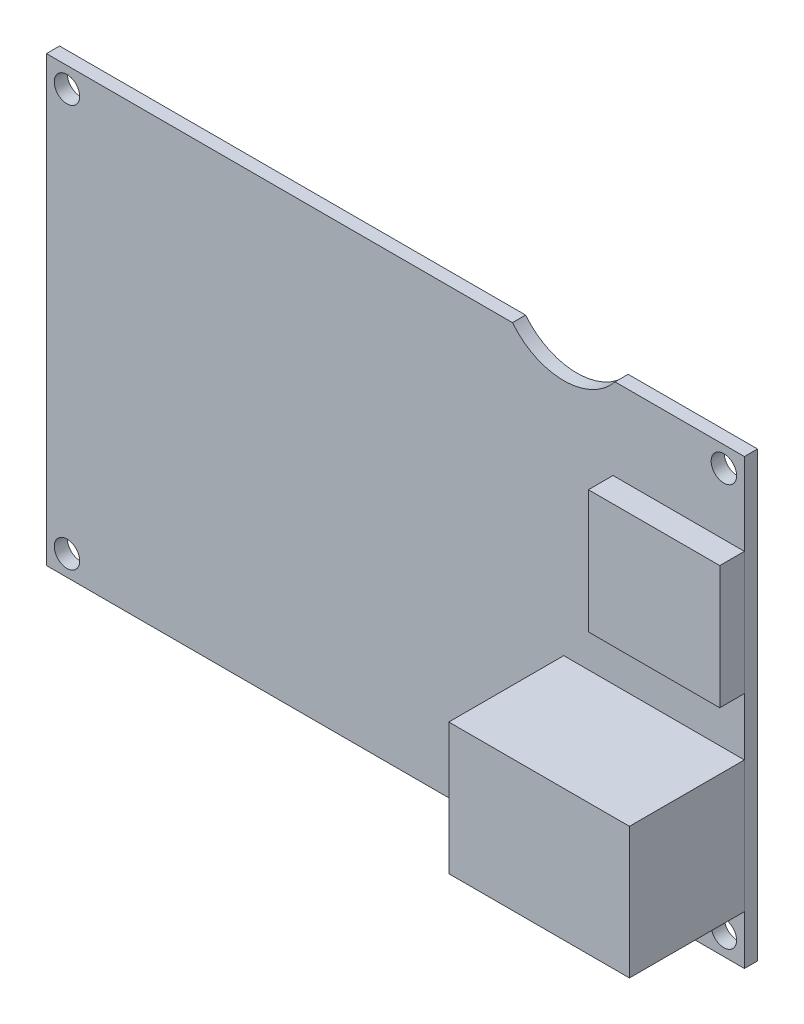
from build123d import *

# Parameters (mm, degrees)
SKETCH_1_W          = 85
SKETCH_1_H          = 54
SKETCH_1_R          = 1.55
EXTRUDE_1_DEPTH     = 1.6
SKETCH_2_W          = 22
SKETCH_2_H          = 16
EXTRUDE_2_DEPTH     = 14
SKETCH_2_3_W        = 16
SKETCH_2_3_H        = 15
EXTRUDE_3_DEPTH     = 3
CUT_EXTRUDE_1_DEPTH = 102.671038157


with BuildPart() as part:
    # Эскиз1 → Бобышка-Вытянуть1 (new body)
    with BuildSketch(Plane.XY):
        with Locations((42.5, 27)):
            Rectangle(SKETCH_1_W, SKETCH_1_H)
        with Locations((2.5, 51.5)):
            Circle(SKETCH_1_R, mode=Mode.SUBTRACT)
        with Locations((82.5, 51.5)):
            Circle(SKETCH_1_R, mode=Mode.SUBTRACT)
        with Locations((82.5, 2.5)):
            Circle(SKETCH_1_R, mode=Mode.SUBTRACT)
        with Locations((2.5, 2.5)):
            Circle(SKETCH_1_R, mode=Mode.SUBTRACT)
    extrude(amount=EXTRUDE_1_DEPTH)

    # Эскиз5 → Вырез-Вытянуть1 (cut, through all)
    with BuildSketch(Plane.XY.offset(1.6)):
        with BuildLine():
            Line((-59.259445708, 198.901998746), (56.755002002, 54))
            ThreePointArc((56.755002002, 54), (63, 51), (69.244997998, 54))
            Line((69.244997998, 54), (185.259445708, 198.901998746))
            Line((185.259445708, 198.901998746), (185.259445708, 570.148231416))
            Line((185.259445708, 570.148231416), (-59.259445708, 570.148231416))
            Line((-59.259445708, 570.148231416), (-59.259445708, 198.901998746))
        make_face()
    extrude(amount=-CUT_EXTRUDE_1_DEPTH, mode=Mode.SUBTRACT)


with BuildPart() as body_2:
    # Эскиз2 → Бобышка-Вытянуть2 (new body)
    with BuildSketch(Plane(origin=(0, 0, 1.6), x_dir=(-1, 0, 0), z_dir=(0, 0, -1))):
        with Locations((-74, 14)):
            Rectangle(SKETCH_2_W, SKETCH_2_H)
    extrude(amount=-EXTRUDE_2_DEPTH)


with BuildPart() as body_3:
    # Эскиз2<3> → Бобышка-Вытянуть3 (new body)
    with BuildSketch(Plane(origin=(0, 0, 1.6), x_dir=(-1, 0, 0), z_dir=(0, 0, -1))):
        with Locations((-77, 36.5)):
            Rectangle(SKETCH_2_3_W, SKETCH_2_3_H)
    extrude(amount=-EXTRUDE_3_DEPTH)


solid = Compound([part.part, body_2.part, body_3.part])
